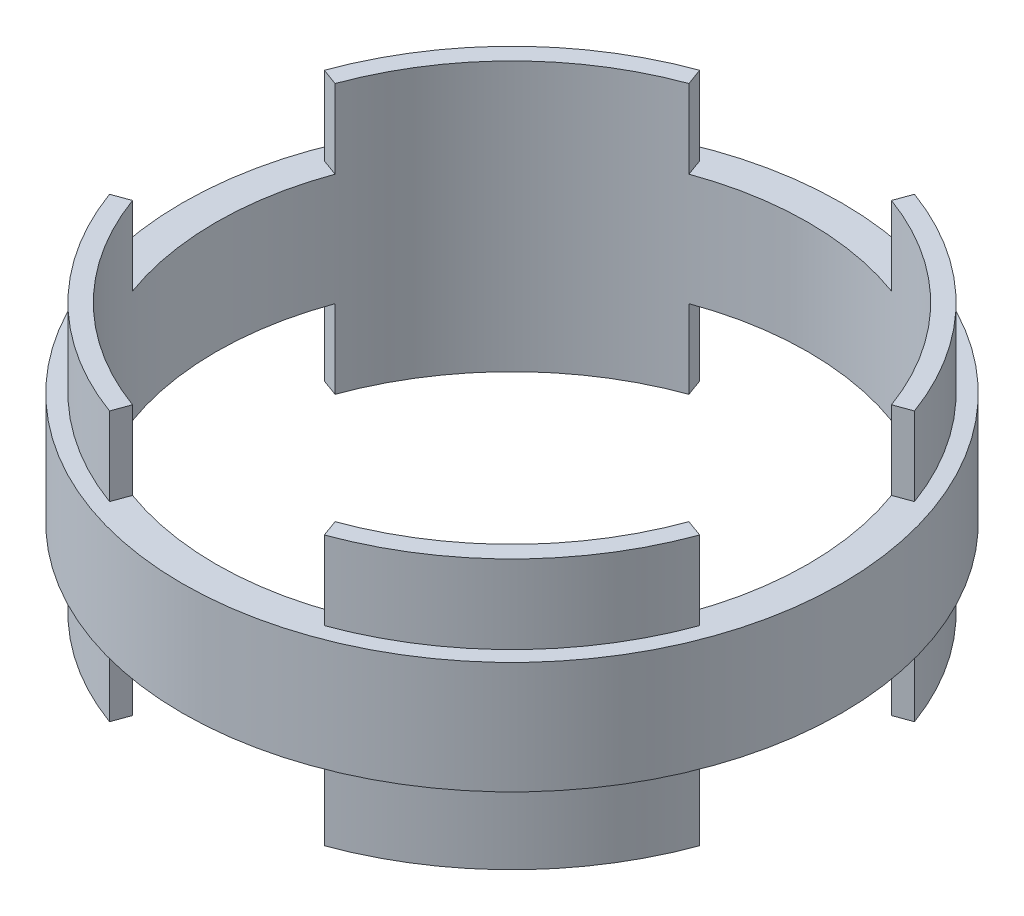
from build123d import *
from build123d.topology import SkipClean

# Parameters (mm, degrees)
SKETCH1_R           = 93.345
SKETCH1_R_2         = 83.82
BOSS_EXTRUDE1_DEPTH = 15.875
SKETCH2_R           = 88.9
SKETCH2_R_2         = 83.82
BOSS_EXTRUDE2_DEPTH = 38.1
CUT_EXTRUDE1_DEPTH  = 38.1
CIRPATTERN1_COUNT   = 4
SKETCH4_R           = 88.9
SKETCH4_R_2         = 83.82
BOSS_EXTRUDE3_DEPTH = 15.875


with BuildPart() as part:
    # Sketch1 → Boss-Extrude1 (new, symmetric)
    with BuildSketch(Plane(origin=(0, 0, 0), x_dir=(1, 0, 0), z_dir=(0, 1, 0))):
        with Locations(Location((0, 0, 0), (0, 0, 270))):
            Circle(SKETCH1_R)
        with Locations(Location((0, 0, 0), (0, 0, 270))):
            Circle(SKETCH1_R_2, mode=Mode.SUBTRACT)
    extrude(amount=BOSS_EXTRUDE1_DEPTH, both=True)

    # Sketch2 → Boss-Extrude2 (add, symmetric)
    with BuildSketch(Plane(origin=(0, 0, 0), x_dir=(1, 0, 0), z_dir=(0, 1, 0))):
        with Locations(Location((0, 0, 0), (0, 0, 90))):
            Circle(SKETCH2_R)
        with Locations(Location((0, 0, 0), (0, 0, 270))):
            Circle(SKETCH2_R_2, mode=Mode.SUBTRACT)
    extrude(amount=BOSS_EXTRUDE2_DEPTH, both=True)

    # Sketch3 → Cut-Extrude1 (cut, symmetric)
    with BuildSketch(Plane(origin=(0, 0, 0), x_dir=(1, 0, 0), z_dir=(0, 1, 0))):
        with BuildLine():
            Line((0, 0), (-30.405590742, 83.538673988))
            ThreePointArc((-30.405590742, 83.538673988), (0, 88.9), (30.405590742, 83.538673988))
            Line((30.405590742, 83.538673988), (0, 0))
        make_face()
    cut_extrude1 = extrude(amount=CUT_EXTRUDE1_DEPTH, both=True, mode=Mode.SUBTRACT)

    # CirPattern1: Cut-Extrude1 ×4 about axis
    cirpattern1_axis = Axis((0, 38.1, 0), (0, -1, 0))
    for i in range(1, CIRPATTERN1_COUNT):
        add(cut_extrude1.rotate(cirpattern1_axis, i * 360 / CIRPATTERN1_COUNT), mode=Mode.SUBTRACT)

    # Sketch4 → Boss-Extrude3 (add, symmetric)
    with SkipClean():  # the faces are left unmerged after this step: merging them gives an invalid solid
        with BuildSketch(Plane(origin=(0, 0, 0), x_dir=(1, 0, 0), z_dir=(0, 1, 0))):
            Circle(SKETCH4_R)
            with Locations(Location((0, 0, 0), (0, 0, 110))):
                Circle(SKETCH4_R_2, mode=Mode.SUBTRACT)
        extrude(amount=BOSS_EXTRUDE3_DEPTH, both=True)


solid = part.part
